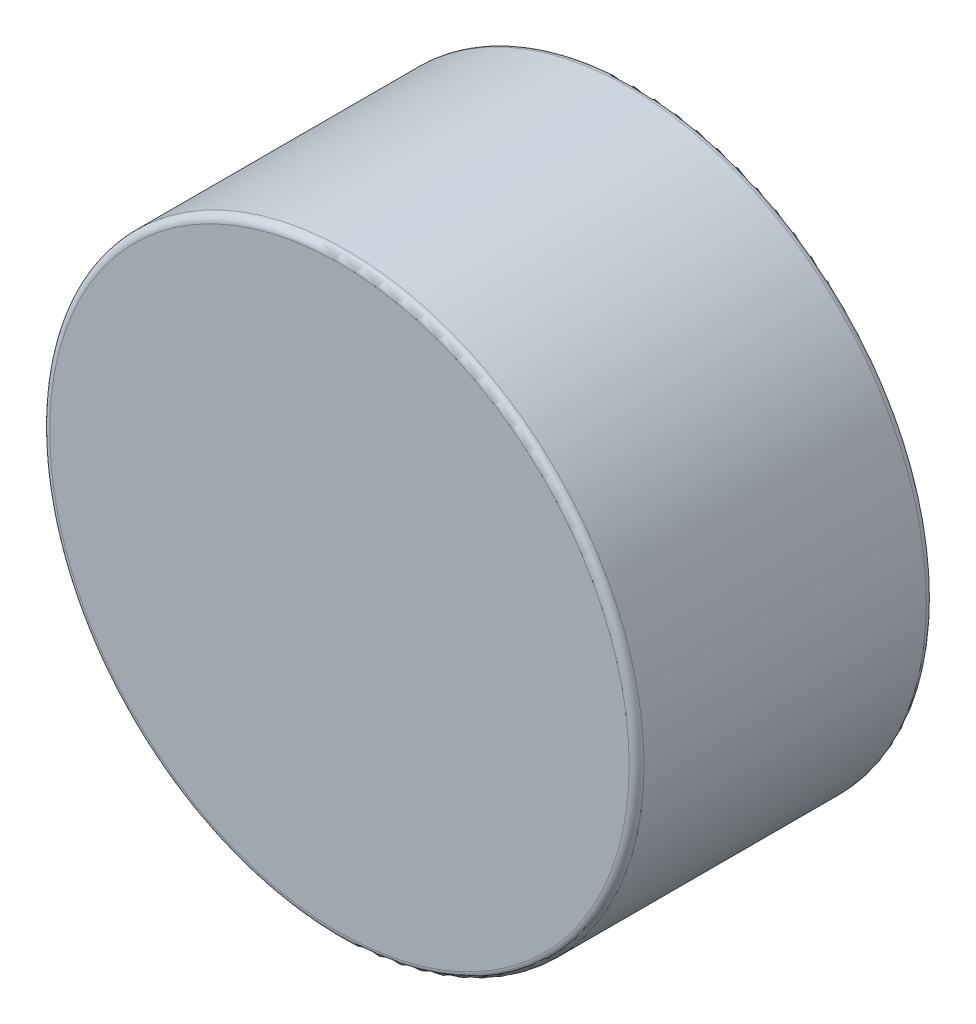
from build123d import *

# Parameters (mm, degrees)
SKETCH3_R                = 1.5875
BOSS_EXTRUDE1_DEPTH      = 0.79375
BOSS_EXTRUDE1_DEPTH_BACK = 0.79375
FILLET1_R                = 0.0396875


with BuildPart() as part:
    # Sketch3 → Boss-Extrude1 (new body, two sides)
    with BuildSketch(Plane.XY) as boss_extrude1_sk:
        Circle(SKETCH3_R)
    extrude(amount=BOSS_EXTRUDE1_DEPTH)
    extrude(boss_extrude1_sk.sketch, amount=-BOSS_EXTRUDE1_DEPTH_BACK)

    # Fillet1
    fillet1_edges = [part.edges().sort_by_distance(p)[0] for p in [
        (-1.5875, 0, -0.79375),
        (-1.5875, 0, 0.79375),
    ]]
    fillet(fillet1_edges, radius=FILLET1_R)


solid = part.part
